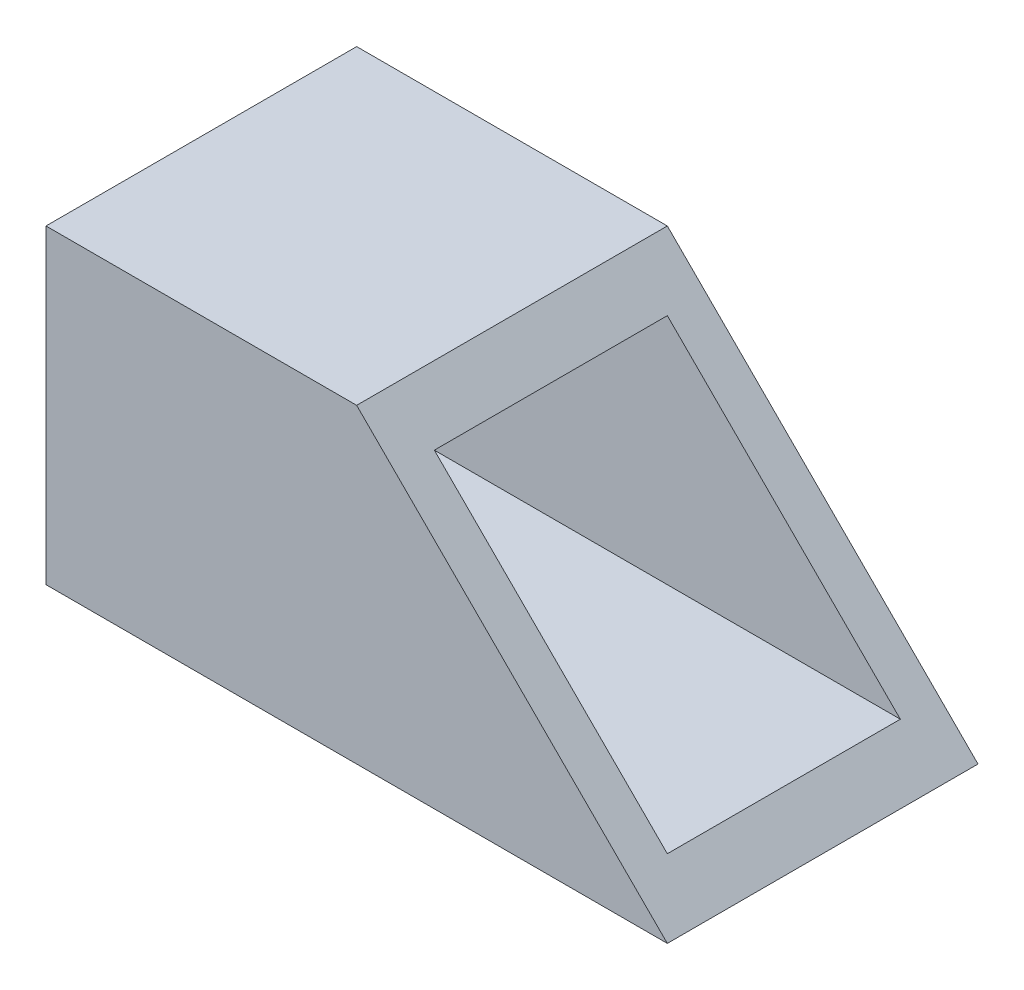
from build123d import *

# Parameters (mm, degrees)
SKETCH1_W           = 25.4
SKETCH1_H           = 25.4
SKETCH1_W_2         = 19.05
SKETCH1_H_2         = 19.05
BOSS_EXTRUDE1_DEPTH = 50.8
CUT_EXTRUDE1_DEPTH  = 26.4


with BuildPart() as part:
    # Sketch1 → Boss-Extrude1 (new body)
    with BuildSketch(Plane(origin=(0, 0, 0), x_dir=(0, 0, -1), z_dir=(1, 0, 0))):
        Rectangle(SKETCH1_W, SKETCH1_H)
        Rectangle(SKETCH1_W_2, SKETCH1_H_2, mode=Mode.SUBTRACT)
    extrude(amount=BOSS_EXTRUDE1_DEPTH)

    # Sketch2 → Cut-Extrude1 (cut, through all)
    with BuildSketch(Plane(origin=(0, 0, -12.7), x_dir=(-1, 0, 0), z_dir=(0, 0, -1))):
        Polygon((-50.8, -12.7), (-25.4, 12.7), (-50.8, 12.7), align=None)
    extrude(amount=-CUT_EXTRUDE1_DEPTH, mode=Mode.SUBTRACT)


solid = part.part
